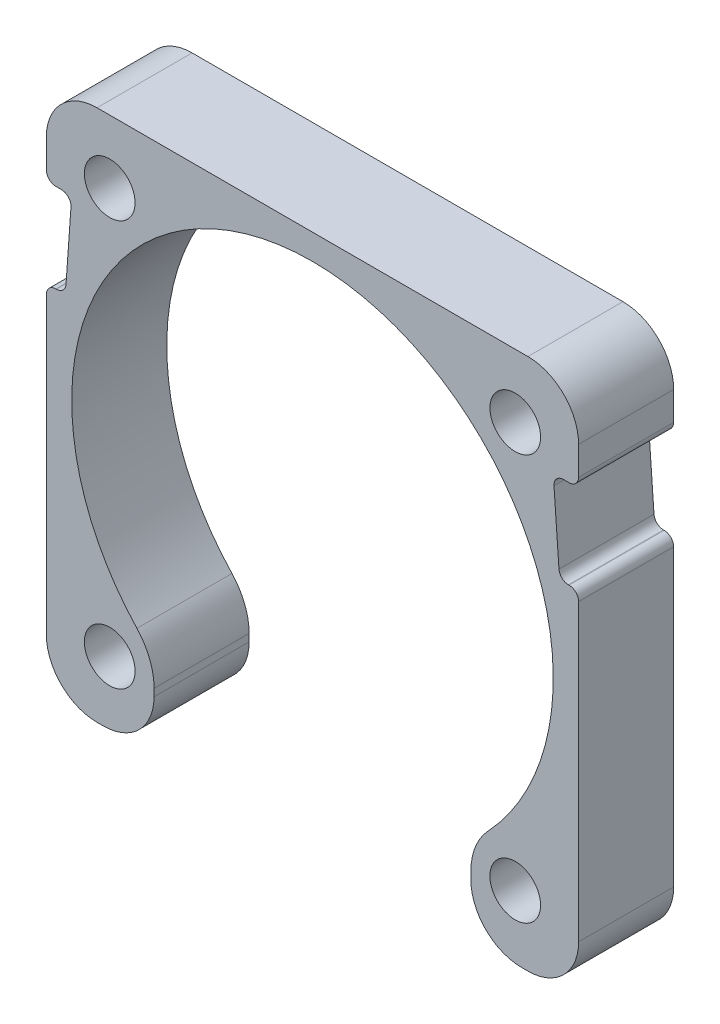
from build123d import *

# Parameters (mm, degrees)
CROQUIS1_W              = 42
CROQUIS1_H              = 42
SALIENTE_EXTRUIR1_DEPTH = 7.5
CROQUIS2_R              = 19
CORTAR_EXTRUIR1_DEPTH   = 8.5
CROQUIS3_R              = 2
CORTAR_EXTRUIR2_DEPTH   = 8.5
CROQUIS4_W              = 25
CROQUIS4_H              = 33.5
CORTAR_EXTRUIR3_DEPTH   = 8.5
REDONDEO1_R             = 4
REDONDEO2_R             = 5
CORTAR_EXTRUIR4_DEPTH   = 8.5
REDONDEO3_R             = 0.75


with BuildPart() as part:
    # Croquis1 → Saliente-Extruir1 (new body)
    with BuildSketch(Plane.XY):
        Rectangle(CROQUIS1_W, CROQUIS1_H)
    extrude(amount=SALIENTE_EXTRUIR1_DEPTH)

    # Croquis2 → Cortar-Extruir1 (cut, through all)
    with BuildSketch(Plane.XY.offset(7.5)):
        Circle(CROQUIS2_R)
    extrude(amount=-CORTAR_EXTRUIR1_DEPTH, mode=Mode.SUBTRACT)

    # Croquis3 → Cortar-Extruir2 (cut, through all)
    with BuildSketch(Plane.XY.offset(7.5)):
        with Locations((-16, 16)):
            Circle(CROQUIS3_R)
        with Locations((16, 16)):
            Circle(CROQUIS3_R)
        with Locations((16, -16)):
            Circle(CROQUIS3_R)
        with Locations((-16, -16)):
            Circle(CROQUIS3_R)
    extrude(amount=-CORTAR_EXTRUIR2_DEPTH, mode=Mode.SUBTRACT)

    # Croquis4 → Cortar-Extruir3 (cut, through all)
    with BuildSketch(Plane.XY.offset(7.5)):
        with Locations((0, -4.25)):
            Rectangle(CROQUIS4_W, CROQUIS4_H)
    extrude(amount=-CORTAR_EXTRUIR3_DEPTH, mode=Mode.SUBTRACT)

    # Redondeo1
    redondeo1_edges = [part.edges().sort_by_distance(p)[0] for p in [
        (-12.5, -21, 3.75),
        (12.5, -21, 3.75),
        (-21, 21, 3.75),
        (21, 21, 3.75),
        (21, -21, 3.75),
        (-21, -21, 3.75),
    ]]
    fillet(redondeo1_edges, radius=REDONDEO1_R)

    # Redondeo2
    redondeo2_edges = [part.edges().sort_by_distance(p)[0] for p in [
        (12.5, -14.309088021, 3.75),
        (-12.5, -14.309088021, 3.75),
    ]]
    fillet(redondeo2_edges, radius=REDONDEO2_R)

    # Croquis5 → Cortar-Extruir4 (cut, through all)
    with BuildSketch(Plane.XY.offset(7.5)):
        Polygon((-21, 7), (-21, 14), (-19, 14), (-19.5, 7), align=None)
        Polygon((21, 14), (19, 14), (19.5, 7), (21, 7), align=None)
    extrude(amount=-CORTAR_EXTRUIR4_DEPTH, mode=Mode.SUBTRACT)

    # Redondeo3
    redondeo3_edges = [part.edges().sort_by_distance(p)[0] for p in [
        (-19.5, 7, 3.75),
        (-21, 7, 3.75),
        (-21, 14, 3.75),
        (-19, 14, 3.75),
        (21, 14, 3.75),
        (21, 7, 3.75),
        (19.5, 7, 3.75),
        (19, 14, 3.75),
    ]]
    fillet(redondeo3_edges, radius=REDONDEO3_R)


solid = part.part
